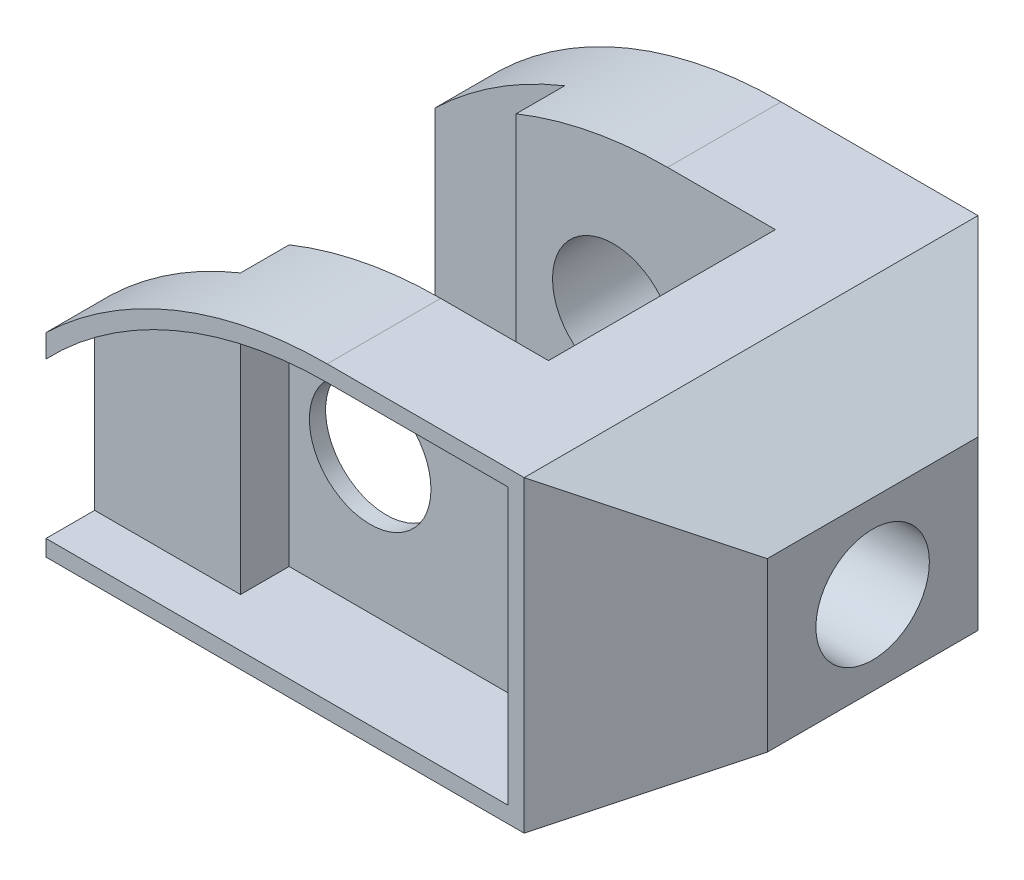
from build123d import *

# Parameters (mm, degrees)
SKETCH1_R           = 7.5
BOSS_EXTRUDE1_DEPTH = 56
CUT_EXTRUDE1_DEPTH  = 38
SKETCH3_R           = 7
CUT_EXTRUDE2_DEPTH  = 26
CUT_EXTRUDE3_DEPTH  = 6
CUT_EXTRUDE4_DEPTH  = 6


with BuildPart() as part:
    # Sketch1 → Boss-Extrude1 (new body)
    with BuildSketch(Plane.XY):
        with BuildLine():
            Line((-28, -19), (31, -19))
            Line((31, -19), (46, -10.339745962))
            Line((46, -10.339745962), (46, 10.339745962))
            Line((46, 10.339745962), (31, 19))
            Line((31, 19), (6.698703146, 19))
            ThreePointArc((6.698703146, 19), (-12.009583788, 15.368092477), (-28, 5))
            Line((-28, 5), (-28, -19))
        make_face()
        Circle(SKETCH1_R, mode=Mode.SUBTRACT)
    extrude(amount=BOSS_EXTRUDE1_DEPTH)

    # Sketch2 → Cut-Extrude1 (cut)
    with BuildSketch(Plane(origin=(0, 19, 0), x_dir=(1, 0, 0), z_dir=(0, 1, 0))):
        Polygon((31, 0), (46, -15), (46, 0), align=None)
        Polygon((31, -56), (46, -41), (46, -56), align=None)
        Polygon((-28, -8), (-12, -8), (-12, -14), (20, -14), (20, -42), (-12, -42), (-12, -48), (-28, -48), align=None)
    extrude(amount=-CUT_EXTRUDE1_DEPTH, mode=Mode.SUBTRACT)

    # Sketch3 → Cut-Extrude2 (cut)
    with BuildSketch(Plane(origin=(46, 0, 0), x_dir=(0, 0, -1), z_dir=(1, 0, 0))):
        with Locations((-28, 0)):
            Circle(SKETCH3_R)
    extrude(amount=-CUT_EXTRUDE2_DEPTH, mode=Mode.SUBTRACT)

    # Sketch7 → Cut-Extrude3 (cut)
    with BuildSketch(Plane.XY.offset(56)):
        with BuildLine():
            Line((-28, 2.166247904), (-28, -17))
            Line((-28, -17), (29, -17))
            Line((29, -17), (29, 17))
            Line((29, 17), (6.698703146, 17))
            ThreePointArc((6.698703146, 17), (-12.169525449, 13.136039125), (-28, 2.166247904))
        make_face()
    extrude(amount=-CUT_EXTRUDE3_DEPTH, mode=Mode.SUBTRACT)

    # Sketch10 → Cut-Extrude4 (cut)
    with BuildSketch(Plane.XY.offset(50)):
        with BuildLine():
            Line((-10, -17), (-10, 14.001703448))
            ThreePointArc((-10, 14.001703448), (-1.784168847, 16.244479918), (6.698703146, 17))
            Line((6.698703146, 17), (29, 17))
            Line((29, 17), (29, -17))
            Line((29, -17), (-10, -17))
        make_face()
    extrude(amount=-CUT_EXTRUDE4_DEPTH, mode=Mode.SUBTRACT)


solid = part.part
